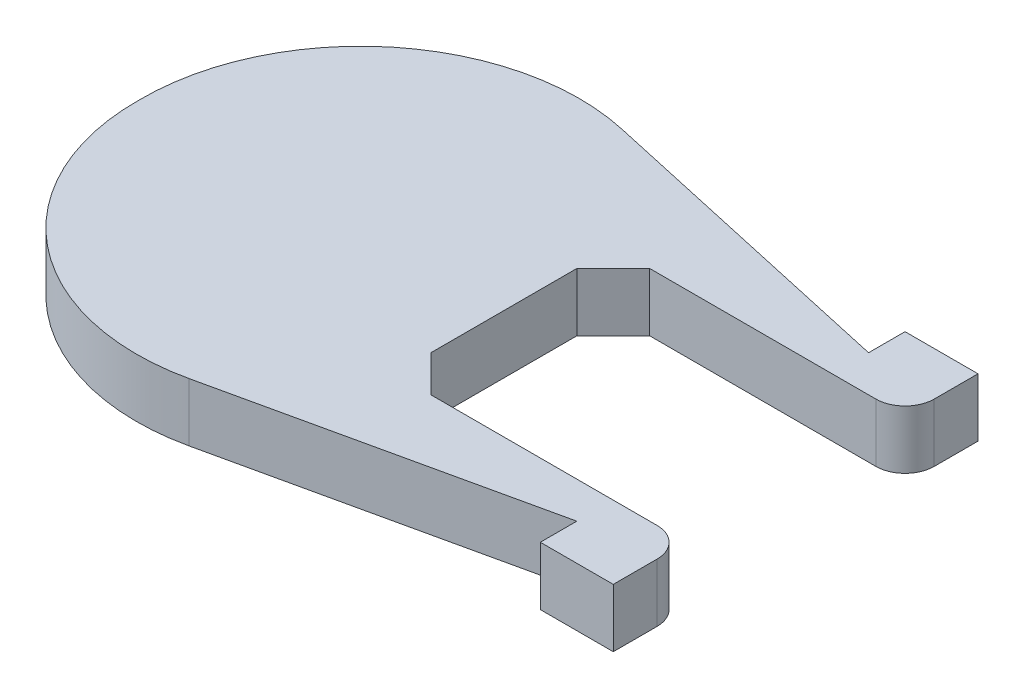
from build123d import *

# Parameters (mm, degrees)
P_IDAT_VYSUNUT_M2_DEPTH = 8


with BuildPart() as part:
    # Skica1 → Přidat vysunutím2 (new body)
    with BuildSketch(Plane(origin=(0, 0, 0), x_dir=(1, 0, 0), z_dir=(0, 1, 0))):
        with BuildLine():
            Line((0, -10), (0, 10))
            Line((0, 10), (5, 15))
            Line((5, 15), (36, 15))
            ThreePointArc((36, 15), (38.828427125, 16.171572875), (40, 19))
            Line((40, 19), (40, 25))
            Line((40, 25), (30, 25))
            Line((30, 25), (30, 20))
            Line((30, 20), (-13.506811582, 29.645227916))
            ThreePointArc((-13.506811582, 29.645227916), (-38.916330448, 23.640944379), (-49.997883531, 0))
            ThreePointArc((-49.997883531, 0), (-38.916330448, -23.640944379), (-13.506811582, -29.645227916))
            Line((-13.506811582, -29.645227916), (30, -20))
            Line((30, -20), (30, -25))
            Line((30, -25), (40, -25))
            Line((40, -25), (40, -19))
            ThreePointArc((40, -19), (38.828427125, -16.171572875), (36, -15))
            Line((36, -15), (5, -15))
            Line((5, -15), (0, -10))
        make_face()
    extrude(amount=P_IDAT_VYSUNUT_M2_DEPTH)


solid = part.part
